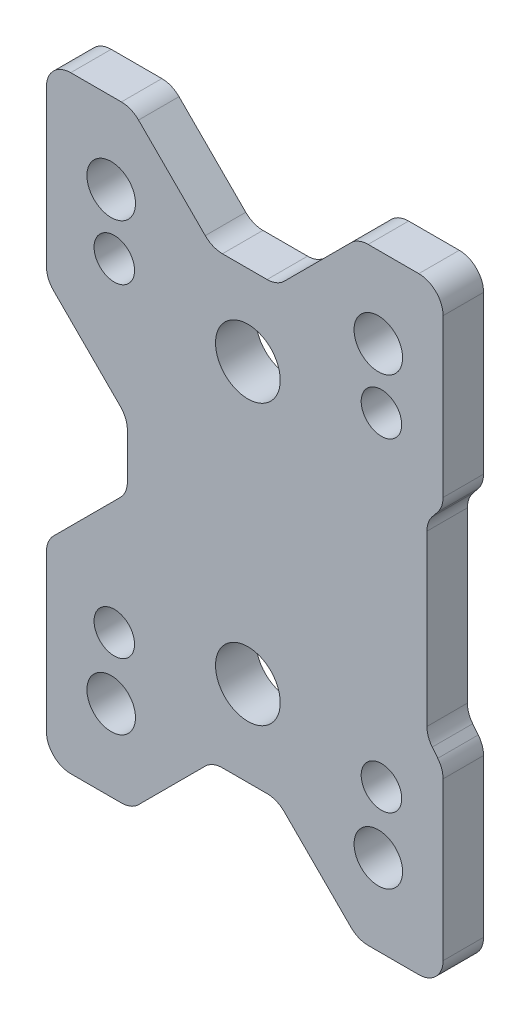
from build123d import *

# Parameters (mm, degrees)
SKETCH2_R           = 3
BOSS_EXTRUDE1_DEPTH = 5
BOSS_EXTRUDE3_DEPTH = 5
CUT_EXTRUDE5_DEPTH  = 6
SKETCH10_R          = 4
SKETCH10_R_2        = 2.5
CUT_EXTRUDE6_DEPTH  = 10


with BuildPart() as part:
    # Sketch2 → Boss-Extrude1 (new body)
    with BuildSketch(Plane.XY):
        with BuildLine():
            Line((-15.626230545, 37.212307607), (-21.883589858, 37.212307607))
            ThreePointArc((-21.883589858, 37.212307607), (-24.004910201, 36.33362795), (-24.883589858, 34.212307607))
            Line((-24.883589858, 34.212307607), (-24.883589858, 14.954948294))
            ThreePointArc((-24.883589858, 14.954948294), (-24.655228455, 13.806897997), (-24.004910201, 12.83362795))
            Line((-24.004910201, 12.83362795), (-15.762269514, 4.590987263))
            ThreePointArc((-15.762269514, 4.590987263), (-15.11195126, 3.617717217), (-14.883589858, 2.46966692))
            Line((-14.883589858, 2.46966692), (-14.883589858, -3.045051706))
            ThreePointArc((-14.883589858, -3.045051706), (-15.11195126, -4.193102003), (-15.762269514, -5.16637205))
            Line((-15.762269514, -5.16637205), (-24.004910201, -13.409012737))
            ThreePointArc((-24.004910201, -13.409012737), (-24.655228455, -14.382282783), (-24.883589858, -15.53033308))
            Line((-24.883589858, -15.53033308), (-24.883589858, -34.787692393))
            ThreePointArc((-24.883589858, -34.787692393), (-24.004910201, -36.909012737), (-21.883589858, -37.787692393))
            Line((-21.883589858, -37.787692393), (-15.626230545, -37.787692393))
            ThreePointArc((-15.626230545, -37.787692393), (-14.478180248, -37.559330991), (-13.504910201, -36.909012737))
            Line((-13.504910201, -36.909012737), (-5.262269514, -28.66637205))
            ThreePointArc((-5.262269514, -28.66637205), (-4.288999468, -28.016053796), (-3.14094917, -27.787692393))
            Line((-3.14094917, -27.787692393), (2.373769455, -27.787692393))
            ThreePointArc((2.373769455, -27.787692393), (3.521819752, -28.016053796), (4.495089799, -28.66637205))
            Line((4.495089799, -28.66637205), (12.737730486, -36.909012737))
            ThreePointArc((12.737730486, -36.909012737), (13.711000532, -37.559330991), (14.85905083, -37.787692393))
            Line((14.85905083, -37.787692393), (21.116410142, -37.787692393))
            ThreePointArc((21.116410142, -37.787692393), (23.237730486, -36.909012737), (24.116410142, -34.787692393))
            Line((24.116410142, -34.787692393), (24.116410142, -15.340035571))
            ThreePointArc((24.116410142, -15.340035571), (23.9472951, -14.347014747), (23.459016571, -13.465950429))
            Line((23.459016571, -13.465950429), (22.773803714, -12.609434358))
            ThreePointArc((22.773803714, -12.609434358), (22.285525185, -11.728370039), (22.116410142, -10.735349215))
            Line((22.116410142, -10.735349215), (22.116410142, 10.159964429))
            ThreePointArc((22.116410142, 10.159964429), (22.285525185, 11.152985253), (22.773803714, 12.034049571))
            Line((22.773803714, 12.034049571), (23.459016571, 12.890565642))
            ThreePointArc((23.459016571, 12.890565642), (23.9472951, 13.771629961), (24.116410142, 14.764650785))
            Line((24.116410142, 14.764650785), (24.116410142, 34.212307607))
            ThreePointArc((24.116410142, 34.212307607), (23.237730486, 36.33362795), (21.116410142, 37.212307607))
            Line((21.116410142, 37.212307607), (14.85905083, 37.212307607))
            ThreePointArc((14.85905083, 37.212307607), (13.711000532, 36.983946204), (12.737730486, 36.33362795))
            Line((12.737730486, 36.33362795), (4.495089799, 28.090987263))
            ThreePointArc((4.495089799, 28.090987263), (3.521819752, 27.440669009), (2.373769455, 27.212307607))
            Line((2.373769455, 27.212307607), (-3.14094917, 27.212307607))
            ThreePointArc((-3.14094917, 27.212307607), (-4.288999468, 27.440669009), (-5.262269514, 28.090987263))
            Line((-5.262269514, 28.090987263), (-13.504910201, 36.33362795))
            ThreePointArc((-13.504910201, 36.33362795), (-14.478180248, 36.983946204), (-15.626230545, 37.212307607))
        make_face()
        with Locations((-16.883589858, -27.787692393)):
            Circle(SKETCH2_R, mode=Mode.SUBTRACT)
        with Locations((16.116410142, -27.787692393)):
            Circle(SKETCH2_R, mode=Mode.SUBTRACT)
        with Locations((16.116410142, 27.212307607)):
            Circle(SKETCH2_R, mode=Mode.SUBTRACT)
        with Locations((-16.883589858, 27.212307607)):
            Circle(SKETCH2_R, mode=Mode.SUBTRACT)
    extrude(amount=BOSS_EXTRUDE1_DEPTH)

    # Sketch7 → Boss-Extrude3 (add, through all)
    with BuildSketch(Plane(origin=(0, 0, 0), x_dir=(-1, 0, 0), z_dir=(0, 0, -1))):
        with BuildLine():
            Line((-24.116410142, 34.488479196), (-29.116410142, 34.488479196))
            ThreePointArc((-29.116410142, 34.488479196), (-32.651944048, 33.024013102), (-34.116410142, 29.488479196))
            Line((-34.116410142, 29.488479196), (-34.116410142, 19.488479196))
            ThreePointArc((-34.116410142, 19.488479196), (-32.651944048, 15.95294529), (-29.116410142, 14.488479196))
            Line((-29.116410142, 14.488479196), (-24.116410142, 14.488479196))
            Line((-24.116410142, 14.488479196), (-24.116410142, 34.488479196))
        make_face()
    extrude(amount=-BOSS_EXTRUDE3_DEPTH)

    # Sketch9 → Cut-Extrude5 (cut, through all)
    with BuildSketch(Plane(origin=(0, 0, 0), x_dir=(-1, 0, 0), z_dir=(0, 0, -1))):
        with BuildLine():
            Line((-24.116410142, 34.488479196), (-24.116410142, 14.488479196))
            Line((-24.116410142, 14.488479196), (-29.116410142, 14.488479196))
            ThreePointArc((-29.116410142, 14.488479196), (-32.651944048, 15.95294529), (-34.116410142, 19.488479196))
            Line((-34.116410142, 19.488479196), (-34.116410142, 29.488479196))
            ThreePointArc((-34.116410142, 29.488479196), (-32.651944048, 33.024013102), (-29.116410142, 34.488479196))
            Line((-29.116410142, 34.488479196), (-24.116410142, 34.488479196))
        make_face()
    extrude(amount=-CUT_EXTRUDE5_DEPTH, mode=Mode.SUBTRACT)

    # Sketch10 → Cut-Extrude6 (cut)
    with BuildSketch(Plane.XY.offset(5)):
        with Locations((0, 17.25)):
            Circle(SKETCH10_R)
        with Locations((0, -17.25)):
            Circle(SKETCH10_R)
        with Locations((16.5, 20)):
            Circle(SKETCH10_R_2)
        with Locations((16.5, -20)):
            Circle(SKETCH10_R_2)
        with Locations((-16.5, -20)):
            Circle(SKETCH10_R_2)
        with Locations((-16.5, 20)):
            Circle(SKETCH10_R_2)
    extrude(amount=-CUT_EXTRUDE6_DEPTH, mode=Mode.SUBTRACT)


solid = part.part
